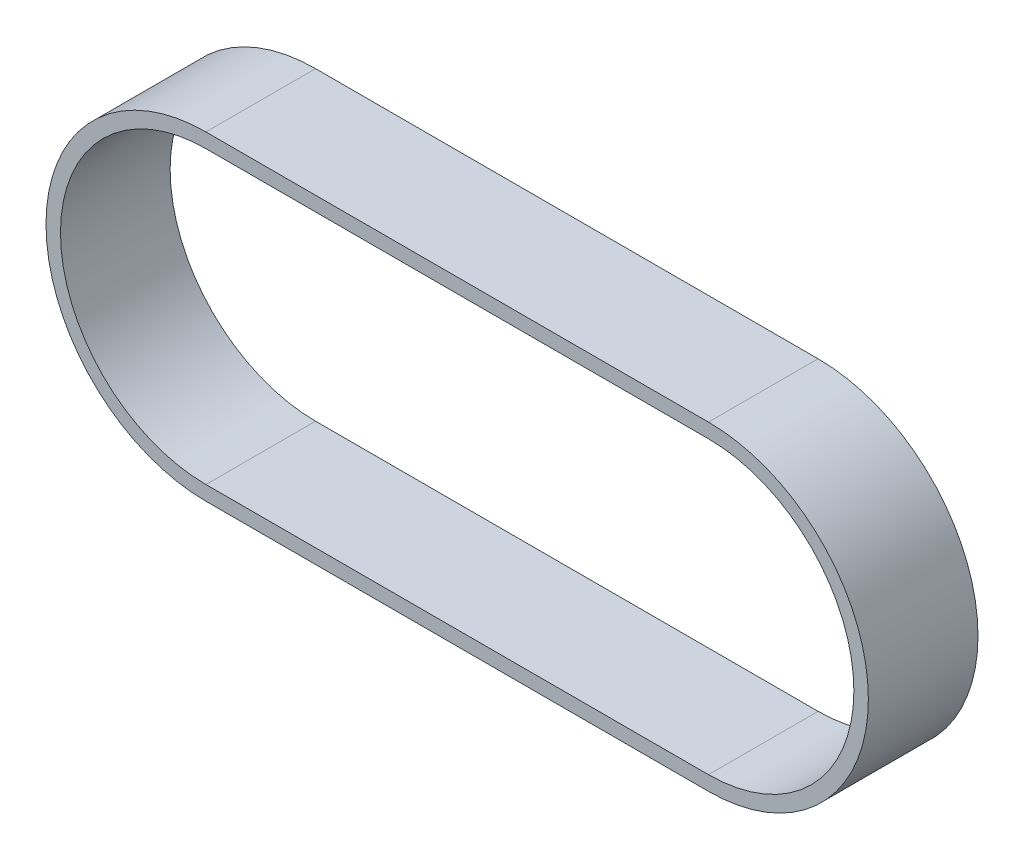
from build123d import *

# Parameters (mm, degrees)
EXTRUSION1_DEPTH = 12


with BuildPart() as part:
    # Esquisse1 → Extrusion1 (new body)
    with BuildSketch(Plane.XY):
        with BuildLine():
            Line((0, 17.5), (55, 17.5))
            ThreePointArc((55, 17.5), (72.5, 0), (55, -17.5))
            Line((55, -17.5), (0, -17.5))
            ThreePointArc((0, -17.5), (-17.5, 0), (0, 17.5))
        make_face()
        with BuildLine():
            Line((0, 15.915), (55, 15.915))
            ThreePointArc((55, 15.915), (70.915, 0), (55, -15.915))
            Line((55, -15.915), (0, -15.915))
            ThreePointArc((0, -15.915), (-15.915, 0), (0, 15.915))
        make_face(mode=Mode.SUBTRACT)
    extrude(amount=EXTRUSION1_DEPTH)


solid = part.part
